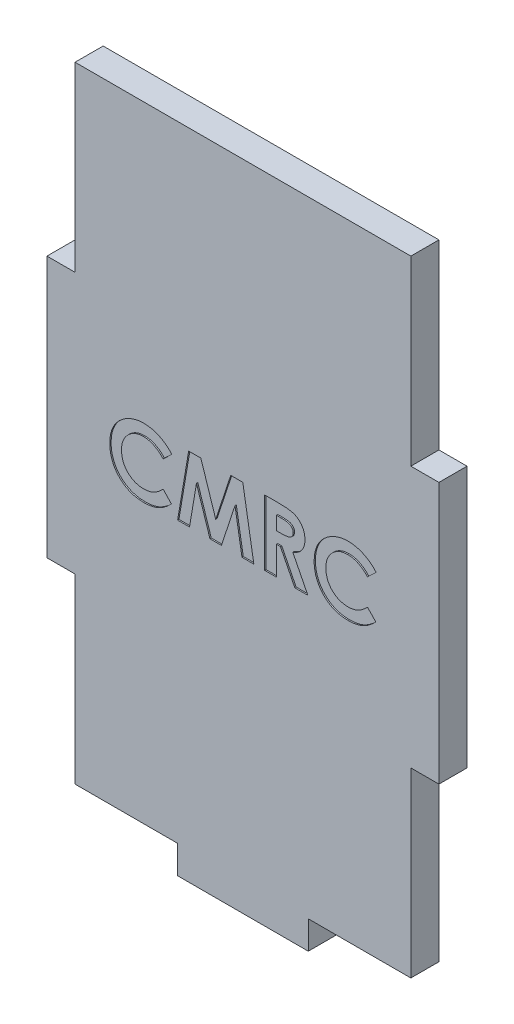
from build123d import *

# Parameters (mm, degrees)
BOSS_EXTRUDE1_DEPTH = 2.7305
CUT_EXTRUDE1_DEPTH  = 0.254


with BuildPart() as part:
    # Sketch1 → Boss-Extrude1 (new body, symmetric)
    with BuildSketch(Plane.XY):
        Polygon((-32.639, -25.4), (-32.639, -60.7695), (-12.7, -60.7695), (-12.7, -66.2305), (12.7, -66.2305), (12.7, -60.7695), (32.639, -60.7695), (32.639, -25.4), (38.1, -25.4), (38.1, 25.4), (32.639, 25.4), (32.639, 60.7695), (-32.639, 60.7695), (-32.639, 25.4), (-38.1, 25.4), (-38.1, -25.4), align=None)
    extrude(amount=BOSS_EXTRUDE1_DEPTH, both=True)

    # Sketch2 → Cut-Extrude1 (cut)
    with BuildSketch(Plane.XY.offset(2.7305)):
        with BuildLine():
            Line((-13.83974359, 4.146834936), (-15.511197917, 2.549158654))
            add(Edge.make_bspline(
                [(-15.511197917, 2.549158654), (-15.65298429, 2.695766001), (-15.929937496, 2.982136081), (-16.376213337, 3.36126483), (-16.840323963, 3.677217344), (-17.313241027, 3.94331054), (-17.803470937, 4.144629007), (-18.3053453, 4.291333165), (-18.822068731, 4.380773146), (-19.171767275, 4.391006662), (-19.34765625, 4.396153846)],
                knots=[0, 0, 0, 0, 0.000611636, 0.001194717, 0.00175289, 0.002293796, 0.002819638, 0.003338934, 0.003860065, 0.00438743, 0.00438743, 0.00438743, 0.00438743], degree=3))
            add(Edge.make_bspline(
                [(-19.34765625, 4.396153846), (-19.494544919, 4.392087391), (-19.784413523, 4.384062689), (-20.210016594, 4.325233713), (-20.617127927, 4.225192477), (-21.007141129, 4.087317123), (-21.378908569, 3.908913733), (-21.733209703, 3.690120387), (-22.069171018, 3.432913099), (-22.382354658, 3.138622671), (-22.668844045, 2.817088264), (-22.921975661, 2.474011819), (-23.134013993, 2.110179305), (-23.308030404, 1.729275349), (-23.443582461, 1.329536941), (-23.54038366, 0.911233199), (-23.596370887, 0.473865956), (-23.604727356, 0.176546964), (-23.608974359, 0.025440705)],
                knots=[0, 0, 0, 0, 0.000440595, 0.000869465, 0.001285963, 0.001696339, 0.002108259, 0.002520595, 0.002943439, 0.003375422, 0.003807899, 0.004233801, 0.004652244, 0.005068921, 0.005488075, 0.005916356, 0.006354978, 0.00680828, 0.00680828, 0.00680828, 0.00680828], degree=3))
            add(Edge.make_bspline(
                [(-23.608974359, 0.025440705), (-23.607750421, -0.08061624), (-23.605338014, -0.289656657), (-23.578929956, -0.598885451), (-23.536406755, -0.898910486), (-23.474865149, -1.189277305), (-23.397906764, -1.470237542), (-23.307617056, -1.744215026), (-23.194349945, -2.007424006), (-23.068621744, -2.262921482), (-22.922401294, -2.503735887), (-22.764748675, -2.733372409), (-22.593800149, -2.95070539), (-22.408448472, -3.154846369), (-22.206085051, -3.342605078), (-21.99194023, -3.519627645), (-21.762401684, -3.681482596), (-21.522237509, -3.832231859), (-21.269372991, -3.963189027), (-21.01066893, -4.08181092), (-20.742202851, -4.178149534), (-20.46724349, -4.255807246), (-20.186773454, -4.321843532), (-19.898049487, -4.362504103), (-19.603574464, -4.393295877), (-19.404558775, -4.395197089), (-19.304407051, -4.396153846)],
                knots=[0, 0, 0, 0, 0.0003181, 0.000626982, 0.000930282, 0.001226664, 0.001516732, 0.001803942, 0.00209123, 0.002375666, 0.002657519, 0.002935557, 0.003210905, 0.003486429, 0.003761812, 0.004038368, 0.004319324, 0.004603828, 0.00488832, 0.005172983, 0.005457066, 0.00574292, 0.006029905, 0.00632062, 0.006617056, 0.006917353, 0.006917353, 0.006917353, 0.006917353], degree=3))
            add(Edge.make_bspline(
                [(-19.304407051, -4.396153846), (-19.134532516, -4.391240173), (-18.800773227, -4.381586083), (-18.31093348, -4.306092468), (-17.844165002, -4.181909743), (-17.471219221, -4.035257161), (-17.179026053, -3.890435832), (-16.956583714, -3.756483235), (-16.726560998, -3.606642547), (-16.492778386, -3.43525862), (-16.252606287, -3.244388129), (-16.010284293, -3.029850654), (-15.759608917, -2.798710606), (-15.595393964, -2.633741413), (-15.511197917, -2.549158654)],
                knots=[0, 0, 0, 0, 0.00050945, 0.001000936, 0.001482902, 0.001955805, 0.002200419, 0.002460463, 0.002734243, 0.003023787, 0.003329721, 0.003654247, 0.003994478, 0.00435247, 0.00435247, 0.00435247, 0.00435247], degree=3))
            Line((-15.511197917, -2.549158654), (-13.890625, -4.251141827))
            add(Edge.make_bspline(
                [(-13.890625, -4.251141827), (-14.004542553, -4.361125648), (-14.226885255, -4.575790546), (-14.562283048, -4.880594671), (-14.89725873, -5.15449506), (-15.223719986, -5.407433098), (-15.547014591, -5.632040086), (-15.867108262, -5.828540341), (-16.180377397, -6.001903638), (-16.493327131, -6.149206291), (-16.807904798, -6.274281543), (-17.13156825, -6.381963125), (-17.465306956, -6.47305787), (-17.81115924, -6.546559365), (-18.165899202, -6.605497641), (-18.532846737, -6.645280637), (-18.909675217, -6.672025422), (-19.165283813, -6.674428662), (-19.294230769, -6.675641026)],
                knots=[0, 0, 0, 0, 0.00047504, 0.000927177, 0.001359107, 0.001772798, 0.00216588, 0.002539382, 0.002899168, 0.003239446, 0.003576283, 0.003914176, 0.004262258, 0.004613543, 0.004974487, 0.005340559, 0.005720478, 0.006107252, 0.006107252, 0.006107252, 0.006107252], degree=3))
            add(Edge.make_bspline(
                [(-19.294230769, -6.675641026), (-19.531090356, -6.669603002), (-19.994558727, -6.657788269), (-20.673759541, -6.570249097), (-21.318982082, -6.423491216), (-21.931796056, -6.215935093), (-22.512006602, -5.950791873), (-23.059465285, -5.625738736), (-23.573289724, -5.241639296), (-24.049329227, -4.802995572), (-24.479929613, -4.318550403), (-24.860530489, -3.798389194), (-25.175363547, -3.239955544), (-25.43677622, -2.651499301), (-25.641197492, -2.030335111), (-25.785075412, -1.375791064), (-25.873803875, -0.688499162), (-25.883510895, -0.21906295), (-25.888461538, 0.020352564)],
                knots=[0, 0, 0, 0, 0.000710452, 0.001390157, 0.002050504, 0.002692507, 0.003327736, 0.003960821, 0.004598876, 0.00524885, 0.005899361, 0.006540548, 0.007178597, 0.007818693, 0.008469542, 0.009136773, 0.009826573, 0.010544546, 0.010544546, 0.010544546, 0.010544546], degree=3))
            add(Edge.make_bspline(
                [(-25.888461538, 0.020352564), (-25.886369637, 0.176497319), (-25.882223998, 0.485938061), (-25.838652957, 0.941769345), (-25.777912391, 1.38612331), (-25.681553007, 1.814386091), (-25.565401274, 2.232327176), (-25.420951332, 2.635404036), (-25.24843389, 3.024775152), (-25.053409589, 3.401092356), (-24.832780549, 3.761890367), (-24.586313691, 4.104069362), (-24.320354033, 4.430270898), (-24.028510997, 4.736167307), (-23.715025445, 5.02444442), (-23.378482027, 5.293540007), (-23.020904881, 5.547313202), (-22.641326181, 5.779219811), (-22.247120128, 5.988991665), (-21.843258699, 6.1740194), (-21.430734134, 6.328659977), (-21.011290625, 6.456928632), (-20.583156027, 6.552672113), (-20.149386257, 6.625146839), (-19.706290455, 6.665660675), (-19.408790011, 6.672293048), (-19.258613782, 6.675641026)],
                knots=[0, 0, 0, 0, 0.000468282, 0.00092802, 0.001372716, 0.001812848, 0.002243728, 0.002673442, 0.003096041, 0.003520474, 0.003944144, 0.004363507, 0.004784695, 0.005205783, 0.005630711, 0.006061404, 0.006497628, 0.006945298, 0.00739485, 0.007836582, 0.008276971, 0.008715592, 0.009151312, 0.009592142, 0.010034144, 0.010484703, 0.010484703, 0.010484703, 0.010484703], degree=3))
            add(Edge.make_bspline(
                [(-19.258613782, 6.675641026), (-19.130498061, 6.673721881), (-18.875598665, 6.669903546), (-18.496010691, 6.638073571), (-18.119458484, 6.588084917), (-17.747290216, 6.512662682), (-17.37684376, 6.423126959), (-17.012987197, 6.305892281), (-16.649980492, 6.175212138), (-16.293516868, 6.019010711), (-15.943098753, 5.848502744), (-15.606935243, 5.655055263), (-15.279382184, 5.45057281), (-14.967697955, 5.222953218), (-14.66604404, 4.980452672), (-14.375997813, 4.721939772), (-14.100104599, 4.443104348), (-13.926969337, 4.246090662), (-13.83974359, 4.146834936)],
                knots=[0, 0, 0, 0, 0.000384289, 0.000764583, 0.001142007, 0.001523193, 0.001903283, 0.002284673, 0.002669392, 0.003060236, 0.003451626, 0.003837864, 0.00422323, 0.004609476, 0.004994876, 0.005384044, 0.005774416, 0.006170768, 0.006170768, 0.006170768, 0.006170768], degree=3))
        make_face()
        Polygon((-10.555348558, 6.35), (-8.189362981, 6.35), (-5.291666667, -2.508453526), (-2.373617788, 6.35), (-0.030528846, 6.35), (2.116666667, -6.35), (-0.190805288, -6.35), (-1.546794872, 1.671454327), (-4.187540064, -6.35), (-6.411057692, -6.35), (-9.036538462, 1.671454327), (-10.389983974, -6.35), (-12.7, -6.35), align=None)
        with BuildLine():
            Line((4.233333333, 6.35), (6.889342949, 6.35))
            add(Edge.make_bspline(
                [(6.889342949, 6.35), (7.064904376, 6.349376858), (7.402558453, 6.34817838), (7.88943719, 6.329269568), (8.336702267, 6.302956405), (8.7450159, 6.262801821), (9.114203406, 6.209561695), (9.444634796, 6.146800397), (9.736300414, 6.075270442), (9.991660055, 5.986138475), (10.222109503, 5.885598967), (10.436920428, 5.770077229), (10.640831877, 5.640859631), (10.832480923, 5.49454611), (11.013533041, 5.33376881), (11.184329797, 5.158365891), (11.342457674, 4.96685001), (11.486937537, 4.760431304), (11.618619303, 4.543283559), (11.734998366, 4.315108629), (11.829638013, 4.075747835), (11.913262287, 3.828660456), (11.973494142, 3.570314331), (12.015384516, 3.303224502), (12.046055009, 3.026450785), (12.047818416, 2.838423011), (12.048717949, 2.742508013)],
                knots=[0, 0, 0, 0, 0.000526647, 0.001012891, 0.001461521, 0.001870602, 0.002243341, 0.002580131, 0.002879392, 0.003143289, 0.003390496, 0.003632932, 0.003874297, 0.004113953, 0.004355439, 0.00460012, 0.00484768, 0.005099659, 0.005355335, 0.005609054, 0.005866998, 0.006126855, 0.00639096, 0.006661566, 0.006937747, 0.007225329, 0.007225329, 0.007225329, 0.007225329], degree=3))
            add(Edge.make_bspline(
                [(12.048717949, 2.742508013), (12.046381286, 2.642394789), (12.041799516, 2.446091003), (12.017119611, 2.157736752), (11.972012498, 1.881859574), (11.903691213, 1.619267204), (11.825164771, 1.366691374), (11.720744745, 1.128792264), (11.602896425, 0.902109978), (11.462931419, 0.689851023), (11.309326662, 0.487300702), (11.130687562, 0.302219471), (10.938587187, 0.124659913), (10.722226876, -0.034256242), (10.491143992, -0.185274332), (10.240747162, -0.322136939), (9.972670561, -0.448284474), (9.784199435, -0.518633054), (9.687820513, -0.554607372)],
                knots=[0, 0, 0, 0, 0.000300373, 0.000588976, 0.000867526, 0.001137785, 0.001402478, 0.001660033, 0.001916088, 0.002168003, 0.002421926, 0.002677475, 0.002938624, 0.003205751, 0.003481663, 0.003766326, 0.004061109, 0.004369613, 0.004369613, 0.004369613, 0.004369613], degree=3))
            Line((9.687820513, -0.554607372), (12.618589744, -6.35))
            Line((12.618589744, -6.35), (10.084695513, -6.35))
            Line((10.084695513, -6.35), (7.286217949, -0.814102564))
            Line((7.286217949, -0.814102564), (6.512820513, -0.814102564))
            Line((6.512820513, -0.814102564), (6.512820513, -6.35))
            Line((6.512820513, -6.35), (4.233333333, -6.35))
            Line((4.233333333, -6.35), (4.233333333, 6.35))
        make_face()
        with BuildLine():
            Line((6.512820513, 1.465384615), (7.400701122, 1.465384615))
            add(Edge.make_bspline(
                [(7.400701122, 1.465384615), (7.509251907, 1.466607187), (7.717103335, 1.46894815), (8.016020989, 1.479806504), (8.287509507, 1.505969773), (8.532734752, 1.539026085), (8.752930675, 1.57719437), (8.946133206, 1.631891842), (9.115319303, 1.690501566), (9.258484102, 1.763338251), (9.380800817, 1.846169359), (9.486413471, 1.940267557), (9.57377028, 2.049174239), (9.645669389, 2.169929791), (9.701599079, 2.303602268), (9.742423467, 2.448724247), (9.765238264, 2.606948855), (9.767863184, 2.716145378), (9.769230769, 2.773036859)],
                knots=[0, 0, 0, 0, 0.000325681, 0.000623609, 0.00089701, 0.00114347, 0.001366015, 0.00156661, 0.001745275, 0.001902288, 0.002046942, 0.002187443, 0.002324917, 0.002464099, 0.002607743, 0.00275836, 0.002915228, 0.003085852, 0.003085852, 0.003085852, 0.003085852], degree=3))
            add(Edge.make_bspline(
                [(9.769230769, 2.773036859), (9.766645223, 2.840343634), (9.761566398, 2.97255532), (9.711168671, 3.162893789), (9.630946375, 3.339065065), (9.52098358, 3.500273162), (9.382499736, 3.641599308), (9.223578599, 3.766179432), (9.040790267, 3.864688072), (8.871542026, 3.929663322), (8.717565688, 3.968538684), (8.5786069, 3.99750826), (8.417691788, 4.018039831), (8.234698868, 4.039817216), (8.030094596, 4.053938747), (7.802763756, 4.064244651), (7.553359242, 4.068461302), (7.379500608, 4.069809291), (7.288762019, 4.070512821)],
                knots=[0, 0, 0, 0, 0.00020156, 0.000395928, 0.000586054, 0.000780105, 0.00097802, 0.001177498, 0.001383584, 0.001598569, 0.001719513, 0.001859714, 0.002024136, 0.002205908, 0.002412543, 0.002639193, 0.002888564, 0.003160792, 0.003160792, 0.003160792, 0.003160792], degree=3))
            Line((7.288762019, 4.070512821), (6.512820513, 4.070512821))
            Line((6.512820513, 4.070512821), (6.512820513, 1.465384615))
        make_face(mode=Mode.SUBTRACT)
        with BuildLine():
            Line((25.888461538, 4.146834936), (24.217007212, 2.549158654))
            add(Edge.make_bspline(
                [(24.217007212, 2.549158654), (24.075220839, 2.695766001), (23.798267632, 2.982136081), (23.351991791, 3.36126483), (22.887881165, 3.677217344), (22.414964101, 3.94331054), (21.924734191, 4.144629007), (21.422859829, 4.291333165), (20.906136397, 4.380773146), (20.556437853, 4.391006662), (20.380548878, 4.396153846)],
                knots=[0, 0, 0, 0, 0.000611636, 0.001194717, 0.00175289, 0.002293796, 0.002819638, 0.003338934, 0.003860065, 0.00438743, 0.00438743, 0.00438743, 0.00438743], degree=3))
            add(Edge.make_bspline(
                [(20.380548878, 4.396153846), (20.233660209, 4.392087391), (19.943791605, 4.384062689), (19.518188534, 4.325233713), (19.111077201, 4.225192477), (18.721063999, 4.087317123), (18.349296559, 3.908913733), (17.994995425, 3.690120387), (17.65903411, 3.432913099), (17.34585047, 3.138622671), (17.059361083, 2.817088264), (16.806229468, 2.474011819), (16.594191135, 2.110179305), (16.420174724, 1.729275349), (16.284622667, 1.329536941), (16.187821468, 0.911233199), (16.131834241, 0.473865956), (16.123477772, 0.176546964), (16.119230769, 0.025440705)],
                knots=[0, 0, 0, 0, 0.000440595, 0.000869465, 0.001285963, 0.001696339, 0.002108259, 0.002520595, 0.002943439, 0.003375422, 0.003807899, 0.004233801, 0.004652244, 0.005068921, 0.005488075, 0.005916356, 0.006354978, 0.00680828, 0.00680828, 0.00680828, 0.00680828], degree=3))
            add(Edge.make_bspline(
                [(16.119230769, 0.025440705), (16.120454707, -0.08061624), (16.122867114, -0.289656657), (16.149275172, -0.598885451), (16.191798373, -0.898910486), (16.25333998, -1.189277305), (16.330298364, -1.470237542), (16.420588072, -1.744215026), (16.533855183, -2.007424006), (16.659583385, -2.262921482), (16.805803835, -2.503735887), (16.963456454, -2.733372409), (17.13440498, -2.95070539), (17.319756656, -3.154846369), (17.522120077, -3.342605078), (17.736264898, -3.519627645), (17.965803444, -3.681482596), (18.205967619, -3.832231859), (18.458832137, -3.963189027), (18.717536198, -4.08181092), (18.986002277, -4.178149534), (19.260961638, -4.255807246), (19.541431674, -4.321843532), (19.830155641, -4.362504103), (20.124630664, -4.393295877), (20.323646353, -4.395197089), (20.423798077, -4.396153846)],
                knots=[0, 0, 0, 0, 0.0003181, 0.000626982, 0.000930282, 0.001226664, 0.001516732, 0.001803942, 0.00209123, 0.002375666, 0.002657519, 0.002935557, 0.003210905, 0.003486429, 0.003761812, 0.004038368, 0.004319324, 0.004603828, 0.00488832, 0.005172983, 0.005457066, 0.00574292, 0.006029905, 0.00632062, 0.006617056, 0.006917353, 0.006917353, 0.006917353, 0.006917353], degree=3))
            add(Edge.make_bspline(
                [(20.423798077, -4.396153846), (20.593672613, -4.391240173), (20.927431901, -4.381586083), (21.417271648, -4.306092468), (21.884040126, -4.181909743), (22.256985907, -4.035257161), (22.549179075, -3.890435832), (22.771621414, -3.756483235), (23.00164413, -3.606642547), (23.235426742, -3.43525862), (23.475598841, -3.244388129), (23.717920835, -3.029850654), (23.968596211, -2.798710606), (24.132811164, -2.633741413), (24.217007212, -2.549158654)],
                knots=[0, 0, 0, 0, 0.00050945, 0.001000936, 0.001482902, 0.001955805, 0.002200419, 0.002460463, 0.002734243, 0.003023787, 0.003329721, 0.003654247, 0.003994478, 0.00435247, 0.00435247, 0.00435247, 0.00435247], degree=3))
            Line((24.217007212, -2.549158654), (25.837580128, -4.251141827))
            add(Edge.make_bspline(
                [(25.837580128, -4.251141827), (25.723662575, -4.361125648), (25.501319873, -4.575790546), (25.16592208, -4.880594671), (24.830946398, -5.15449506), (24.504485143, -5.407433098), (24.181190537, -5.632040086), (23.861096866, -5.828540341), (23.547827731, -6.001903638), (23.234877997, -6.149206291), (22.92030033, -6.274281543), (22.596636878, -6.381963125), (22.262898172, -6.47305787), (21.917045889, -6.546559365), (21.562305926, -6.605497641), (21.195358391, -6.645280637), (20.818529911, -6.672025422), (20.562921315, -6.674428662), (20.433974359, -6.675641026)],
                knots=[0, 0, 0, 0, 0.00047504, 0.000927177, 0.001359107, 0.001772798, 0.00216588, 0.002539382, 0.002899168, 0.003239446, 0.003576283, 0.003914176, 0.004262258, 0.004613543, 0.004974487, 0.005340559, 0.005720478, 0.006107252, 0.006107252, 0.006107252, 0.006107252], degree=3))
            add(Edge.make_bspline(
                [(20.433974359, -6.675641026), (20.197114773, -6.669603002), (19.733646401, -6.657788269), (19.054445588, -6.570249097), (18.409223046, -6.423491216), (17.796409072, -6.215935093), (17.216198526, -5.950791873), (16.668739843, -5.625738736), (16.154915405, -5.241639296), (15.678875901, -4.802995572), (15.248275515, -4.318550403), (14.867674639, -3.798389194), (14.552841581, -3.239955544), (14.291428908, -2.651499301), (14.087007637, -2.030335111), (13.943129716, -1.375791064), (13.854401253, -0.688499162), (13.844694233, -0.21906295), (13.83974359, 0.020352564)],
                knots=[0, 0, 0, 0, 0.000710452, 0.001390157, 0.002050504, 0.002692507, 0.003327736, 0.003960821, 0.004598876, 0.00524885, 0.005899361, 0.006540548, 0.007178597, 0.007818693, 0.008469542, 0.009136773, 0.009826573, 0.010544546, 0.010544546, 0.010544546, 0.010544546], degree=3))
            add(Edge.make_bspline(
                [(13.83974359, 0.020352564), (13.841835492, 0.176497319), (13.84598113, 0.485938061), (13.889552171, 0.941769345), (13.950292737, 1.38612331), (14.046652121, 1.814386091), (14.162803855, 2.232327176), (14.307253796, 2.635404036), (14.479771239, 3.024775152), (14.674795539, 3.401092356), (14.895424579, 3.761890367), (15.141891437, 4.104069362), (15.407851095, 4.430270898), (15.699694131, 4.736167307), (16.013179683, 5.02444442), (16.349723101, 5.293540007), (16.707300247, 5.547313202), (17.086878947, 5.779219811), (17.481085, 5.988991665), (17.884946429, 6.1740194), (18.297470994, 6.328659977), (18.716914503, 6.456928632), (19.145049101, 6.552672113), (19.578818871, 6.625146839), (20.021914673, 6.665660675), (20.319415117, 6.672293048), (20.469591346, 6.675641026)],
                knots=[0, 0, 0, 0, 0.000468282, 0.00092802, 0.001372716, 0.001812848, 0.002243728, 0.002673442, 0.003096041, 0.003520474, 0.003944144, 0.004363507, 0.004784695, 0.005205783, 0.005630711, 0.006061404, 0.006497628, 0.006945298, 0.00739485, 0.007836582, 0.008276971, 0.008715592, 0.009151312, 0.009592142, 0.010034144, 0.010484703, 0.010484703, 0.010484703, 0.010484703], degree=3))
            add(Edge.make_bspline(
                [(20.469591346, 6.675641026), (20.597707067, 6.673721881), (20.852606463, 6.669903546), (21.232194437, 6.638073571), (21.608746644, 6.588084917), (21.980914912, 6.512662682), (22.351361368, 6.423126959), (22.715217931, 6.305892281), (23.078224636, 6.175212138), (23.43468826, 6.019010711), (23.785106375, 5.848502744), (24.121269885, 5.655055263), (24.448822944, 5.45057281), (24.760507173, 5.222953218), (25.062161088, 4.980452672), (25.352207315, 4.721939772), (25.628100529, 4.443104348), (25.801235791, 4.246090662), (25.888461538, 4.146834936)],
                knots=[0, 0, 0, 0, 0.000384289, 0.000764583, 0.001142007, 0.001523193, 0.001903283, 0.002284673, 0.002669392, 0.003060236, 0.003451626, 0.003837864, 0.00422323, 0.004609476, 0.004994876, 0.005384044, 0.005774416, 0.006170768, 0.006170768, 0.006170768, 0.006170768], degree=3))
        make_face()
    extrude(amount=-CUT_EXTRUDE1_DEPTH, mode=Mode.SUBTRACT)


solid = part.part
